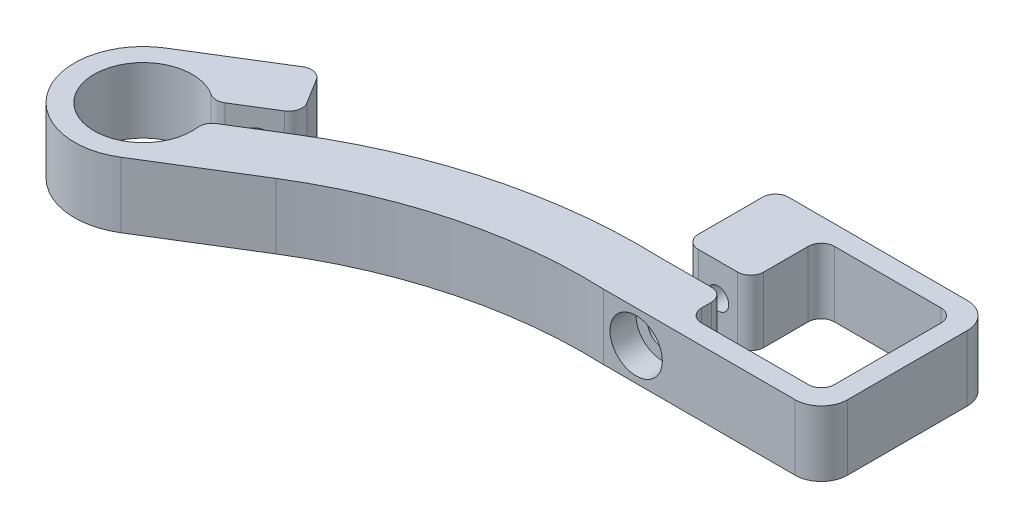
from build123d import *

# Parameters (mm, degrees)
EXTRUDE_2_DEPTH             = 10
HOLE_WIZARD_M41_D           = 4.5
HOLE_WIZARD_M41_DEPTH       = 8.5
HOLE_WIZARD_M41_CBORE_D     = 8
HOLE_WIZARD_M41_CBORE_DEPTH = 4
HOLE_WIZARD_M41_2_REACH     = 112.256
HOLE_WIZARD_M41_2_BORE_R    = 2.25
FILLET_4_R                  = 4
FILLET_3_R                  = 2


with BuildPart() as part:
    # Эскиз1 → Бобышка-Вытянуть2 (new body)
    with BuildSketch(Plane(origin=(0, 0, 0), x_dir=(1, 0, 0), z_dir=(0, 1, 0))):
        with BuildLine():
            Line((3, 3), (-23.3, 3))
            Line((-23.3, 3), (-30.3, 3))
            Line((-30.3, 3), (-30.3, -10.8))
            Line((-30.3, -10.8), (-20.3, -10.8))
            Line((-20.3, -10.8), (-20.3, 0))
            Line((-20.3, 0), (0, 0))
            Line((0, 0), (0, -20.3))
            Line((0, -20.3), (-20.3, -20.3))
            Line((-20.3, -20.3), (-20.3, -14.8))
            Line((-20.3, -14.8), (-30.3, -14.8))
            ThreePointArc((-30.3, -14.8), (-53.235137158, -17.347468756), (-74.439305098, -26.452048677))
            Line((-74.439305098, -26.452048677), (-82.948576893, -31.704885388))
            ThreePointArc((-82.948576893, -31.704885388), (-96.531953846, -37.739627534), (-85.049711578, -28.30117667))
            Line((-85.049711578, -28.30117667), (-76.540439783, -23.048339959))
            Line((-76.540439783, -23.048339959), (-81.005350987, -15.815458933))
            Line((-81.005350987, -15.815458933), (-95.665478547, -24.865264615))
            ThreePointArc((-95.665478547, -24.865264615), (-99.084735385, -39.315478547), (-84.634521453, -42.734735385))
            Line((-84.634521453, -42.734735385), (-69.974393893, -33.684929703))
            ThreePointArc((-69.974393893, -33.684929703), (-50.914097819, -25.524407087), (-30.3, -23.3))
            Line((-30.3, -23.3), (-23.3, -23.3))
            Line((-23.3, -23.3), (3, -23.3))
            Line((3, -23.3), (3, 3))
        make_face()
    extrude(amount=EXTRUDE_2_DEPTH)

    # Эскиз4 → Отверстие обработанное метчиком M4x0.72 (revolve, cut)
    with BuildSketch(Plane(origin=(-25.3, 5, 10.8), x_dir=(0, -1, 0), z_dir=(1, 0, 0))):
        Polygon((0, 0), (0, 9.591420021), (1.65, 8.6), (1.65, 0), align=None)
    revolve(axis=Axis((-25.3, 5, 17.15), (0, 0, -1)), mode=Mode.SUBTRACT)

    # Эскиз6 → Отверстие обработанное метчиком M4x0.71 (revolve, cut)
    with BuildSketch(Plane(origin=(-78.693940996, 5, 29.078467033), x_dir=(-0.8509271795055905, 0, 0.5252836711517509), z_dir=(0, 1, 0))):
        Polygon((0, 0), (0, 8.491420021), (1.65, 7.5), (1.65, 0), align=None)
    revolve(axis=Axis((-82.029492307, 5, 23.675079443), (0.5252836711517508, 0, 0.8509271795055904)), mode=Mode.SUBTRACT)

    # Hole Wizard M41
    with Locations(Plane(origin=(-25.3, 5, 23.3), x_dir=(1, 0, 0), z_dir=(0, 0, 1))):
        with Locations((0, 0)):
            CounterBoreHole(HOLE_WIZARD_M41_D / 2, HOLE_WIZARD_M41_CBORE_D / 2, HOLE_WIZARD_M41_CBORE_DEPTH, depth=HOLE_WIZARD_M41_DEPTH)

    # Hole Wizard M41 2 bore → Hole Wizard M41 2 (cut, up to next)
    with BuildSketch(Plane(origin=(-15.282069591, 0, -24.756011063), x_dir=(-0.8509271795055892, 0, 0.525283671151753), z_dir=(-0.525283671151753, 0, -0.8509271795055892)), mode=Mode.PRIVATE) as hole_wizard_m41_2_sk1:
        with Locations((82.23725717, 5)):
            Circle(HOLE_WIZARD_M41_2_BORE_R)
    hole_wizard_m41_2_tool1 = extrude(hole_wizard_m41_2_sk1.sketch, amount=-HOLE_WIZARD_M41_2_REACH, mode=Mode.PRIVATE) & part.part
    add(hole_wizard_m41_2_tool1.solids().sort_by_distance((-85.259987, 5, 18.441877))[0], mode=Mode.SUBTRACT)

    # Скругление4
    fillet_4_edges = [part.edges().sort_by_distance(p)[0] for p in [
        (3, 5, -3),
        (3, 5, 23.3),
    ]]
    fillet(fillet_4_edges, radius=FILLET_4_R)

    # Скругление3
    fillet_3_edges = [part.edges().sort_by_distance(p)[0] for p in [
        (0, 5, 0),
        (-20.3, 5, 0),
        (-20.3, 5, 10.8),
        (-30.3, 5, 10.8),
        (-30.3, 5, -3),
        (-81.005350987, 5, 15.815458933),
        (-76.540439783, 5, 23.048339959),
        (-85.049711578, 5, 28.30117667),
        (-82.948576893, 5, 31.704885388),
        (-20.3, 5, 14.8),
        (-20.3, 5, 20.3),
        (0, 5, 20.3),
    ]]
    fillet(fillet_3_edges, radius=FILLET_3_R)


solid = part.part
